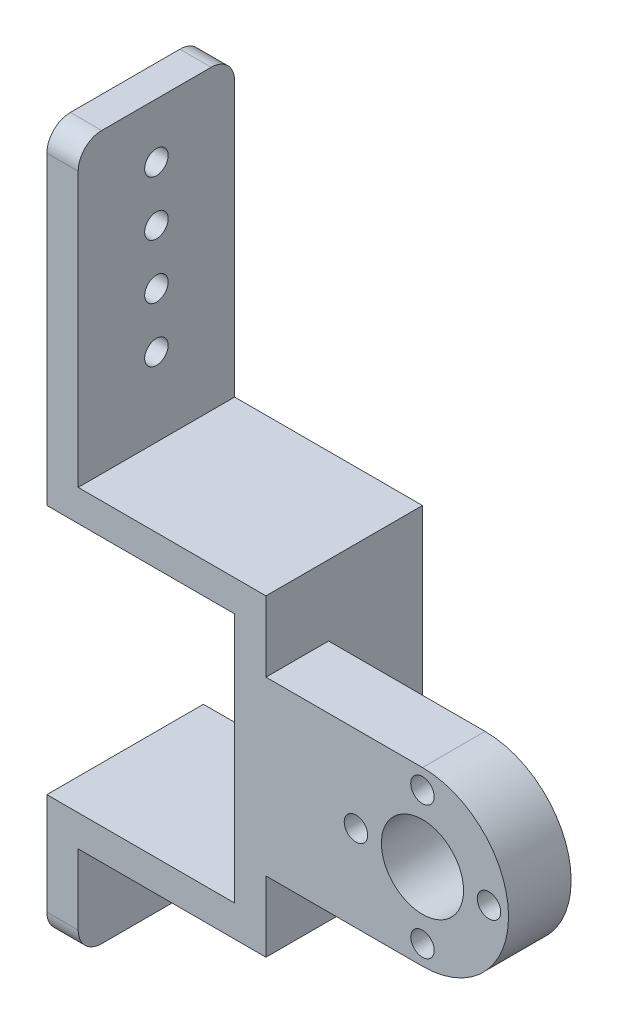
from build123d import *

# Parameters (mm, degrees)
BOSS_EXTRUDE2_DEPTH = 8
SKETCH3_R           = 5.25
CUT_EXTRUDE1_DEPTH  = 8
SKETCH7_W           = 4
SKETCH7_H           = 9
BOSS_EXTRUDE3_DEPTH = 8
SKETCH8_W           = 4
SKETCH8_H           = 40
BOSS_EXTRUDE4_DEPTH = 12
SKETCH9_W           = 20
SKETCH9_H           = 4
BOSS_EXTRUDE5_DEPTH = 24
SKETCH10_W          = 20
SKETCH10_H          = 4
BOSS_EXTRUDE6_DEPTH = 24
SKETCH12_W          = 4
SKETCH12_H          = 38
BOSS_EXTRUDE7_DEPTH = 20
SKETCH13_W          = 4
SKETCH13_H          = 20
BOSS_EXTRUDE8_DEPTH = 12
SKETCH14_R          = 1.5
CUT_EXTRUDE2_DEPTH  = 12
SKETCH15_R          = 1.5
CUT_EXTRUDE3_DEPTH  = 12
FILLET1_R           = 3
SKETCH16_R          = 1.5
CUT_EXTRUDE4_DEPTH  = 12


with BuildPart() as part:
    # Sketch1 → Boss-Extrude2 (new body)
    with BuildSketch(Plane.XY):
        with BuildLine():
            ThreePointArc((12, 11), (1, 0), (12, -11))
            Line((12, -11), (12, 11))
        make_face()
        with BuildLine():
            Line((12, 11), (12, -11))
            ThreePointArc((12, -11), (19.778174593, -7.778174593), (23, 0))
            ThreePointArc((23, 0), (19.778174593, 7.778174593), (12, 11))
        make_face()
        with BuildLine():
            Line((-12, 11), (-12, -11))
            Line((-12, -11), (12, -11))
            ThreePointArc((12, -11), (1, 0), (12, 11))
            Line((12, 11), (-12, 11))
        make_face()
    extrude(amount=BOSS_EXTRUDE2_DEPTH)

    # Sketch3 → Cut-Extrude1 (cut)
    with BuildSketch(Plane.XY.offset(8)):
        with Locations((12, 0)):
            Circle(SKETCH3_R)
    extrude(amount=-CUT_EXTRUDE1_DEPTH, mode=Mode.SUBTRACT)

    # Sketch7 → Boss-Extrude3 (add)
    with BuildSketch(Plane.XY.offset(8)):
        with Locations((-10, 15.5)):
            Rectangle(SKETCH7_W, SKETCH7_H)
        with Locations((-10, -15.5)):
            Rectangle(SKETCH7_W, SKETCH7_H)
    extrude(amount=-BOSS_EXTRUDE3_DEPTH)

    # Sketch8 → Boss-Extrude4 (add)
    with BuildSketch(Plane(origin=(0, 0, 0), x_dir=(-1, 0, 0), z_dir=(0, 0, -1))):
        with Locations((10, 0)):
            Rectangle(SKETCH8_W, SKETCH8_H)
    extrude(amount=BOSS_EXTRUDE4_DEPTH)

    # Sketch9 → Boss-Extrude5 (add)
    with BuildSketch(Plane.ZY.offset(12)):
        with Locations((-2, 18)):
            Rectangle(SKETCH9_W, SKETCH9_H)
    extrude(amount=BOSS_EXTRUDE5_DEPTH)

    # Sketch10 → Boss-Extrude6 (add)
    with BuildSketch(Plane.ZY.offset(12)):
        with Locations((-2, -18)):
            Rectangle(SKETCH10_W, SKETCH10_H)
    extrude(amount=BOSS_EXTRUDE6_DEPTH)

    # Sketch12 → Boss-Extrude7 (add)
    with BuildSketch(Plane(origin=(0, 0, -12), x_dir=(-1, 0, 0), z_dir=(0, 0, -1))):
        with Locations((34, 39)):
            Rectangle(SKETCH12_W, SKETCH12_H)
    extrude(amount=-BOSS_EXTRUDE7_DEPTH)

    # Sketch13 → Boss-Extrude8 (add)
    with BuildSketch(Plane.XZ.offset(20)):
        with Locations((-34, -2)):
            Rectangle(SKETCH13_W, SKETCH13_H)
    extrude(amount=BOSS_EXTRUDE8_DEPTH)

    # Sketch14 → Cut-Extrude2 (cut)
    with BuildSketch(Plane.ZY.offset(36)):
        with Locations((-2, -27.5)):
            Circle(SKETCH14_R)
    extrude(amount=-CUT_EXTRUDE2_DEPTH, mode=Mode.SUBTRACT)

    # Sketch15 → Cut-Extrude3 (cut)
    with BuildSketch(Plane.ZY.offset(36)):
        with Locations((-2, 51)):
            Circle(SKETCH15_R)
        with Locations((-2, 44)):
            Circle(SKETCH15_R)
        with Locations((-2, 37)):
            Circle(SKETCH15_R)
        with Locations((-2, 30)):
            Circle(SKETCH15_R)
    extrude(amount=-CUT_EXTRUDE3_DEPTH, mode=Mode.SUBTRACT)

    # Fillet1
    fillet1_edges = [part.edges().sort_by_distance(p)[0] for p in [
        (-34, -32, -12),
        (-34, -32, 8),
        (-34, 58, 8),
        (-34, 58, -12),
    ]]
    fillet(fillet1_edges, radius=FILLET1_R)

    # Sketch16 → Cut-Extrude4 (cut)
    with BuildSketch(Plane(origin=(0, 0, 0), x_dir=(-1, 0, 0), z_dir=(0, 0, -1))):
        with Locations((-12, 8.5)):
            Circle(SKETCH16_R)
        with Locations((-20.5, 0)):
            Circle(SKETCH16_R)
        with Locations((-12, -8.5)):
            Circle(SKETCH16_R)
        with Locations((-3.5, 0)):
            Circle(SKETCH16_R)
    extrude(amount=-CUT_EXTRUDE4_DEPTH, mode=Mode.SUBTRACT)


solid = part.part
